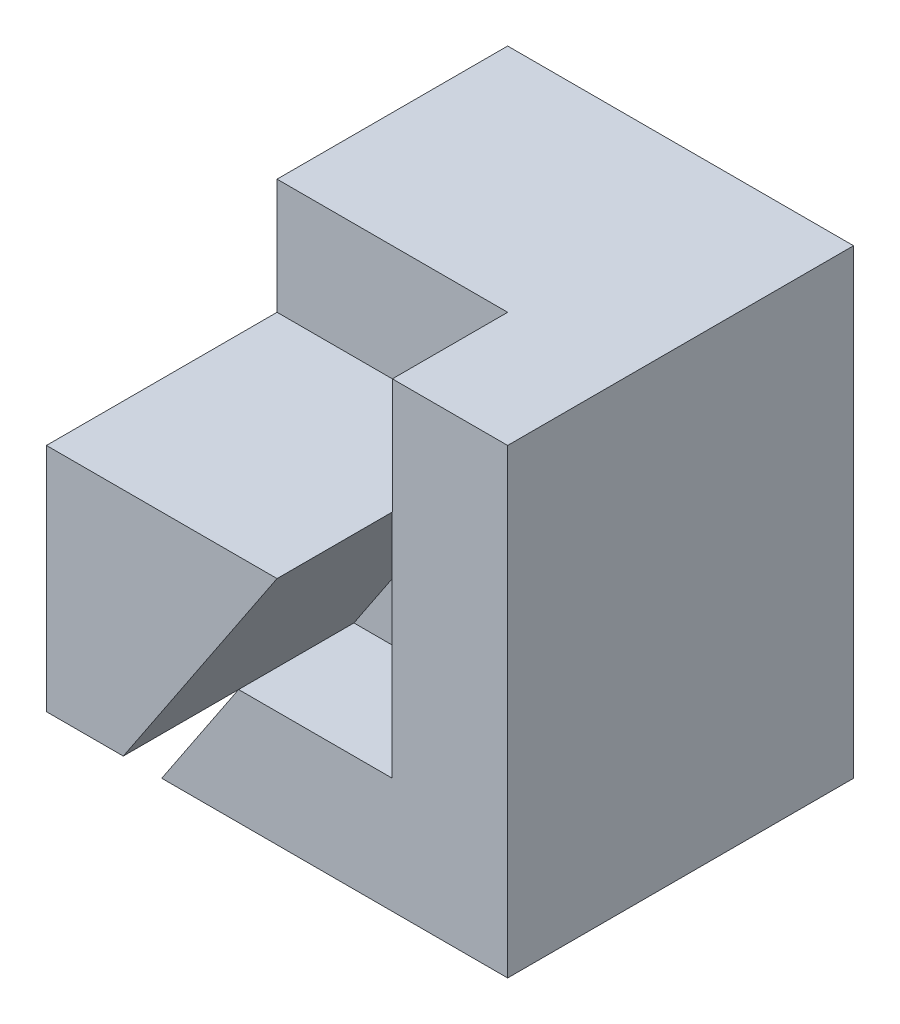
from build123d import *

# Parameters (mm, degrees)
SKETCH1_W            = 40
SKETCH1_H            = 40
BOSS_EXTRUDE1_DEPTH  = 40
SKETCH2_W            = 10
SKETCH2_H            = 10
CUT_EXTRUDE1_DEPTH   = 40
SKETCH4_W            = 10
SKETCH4_H            = 10
SKETCH4_H_2          = 30
CUT_EXTRUDE2_DEPTH   = 40
SKETCH5_W            = 20
SKETCH5_H            = 10
CUT_EXTRUDE3_DEPTH   = 10
SKETCH7_W            = 20
SKETCH7_H            = 10
CUT_EXTRUDE16_DEPTH  = 20
SKETCH11_W           = 20
SKETCH11_H           = 20
CUT_EXTRUDE19_DEPTH  = 10
CUT_EXTRUDE20_DEPTH  = 10
SKETCH13_W           = 20
SKETCH13_H           = 10
CUT_EXTRUDE21_DEPTH  = 10
BOSS_EXTRUDE2_DEPTH  = 10
SKETCH16_W           = 20
SKETCH16_H           = 20
CUT_EXTRUDE25_DEPTH  = 10
CUT_EXTRUDE26_DEPTH  = 10
SKETCH22_W           = 20
SKETCH22_H           = 10
BOSS_EXTRUDE5_DEPTH  = 10
BOSS_EXTRUDE6_DEPTH  = 10
SKETCH24_W           = 20
SKETCH24_H           = 20
BOSS_EXTRUDE7_DEPTH  = 10
BOSS_EXTRUDE8_DEPTH  = 10
BOSS_EXTRUDE9_DEPTH  = 10
CUT_EXTRUDE27_DEPTH  = 10
BOSS_EXTRUDE12_DEPTH = 10
CUT_EXTRUDE30_DEPTH  = 20
CUT_EXTRUDE31_DEPTH  = 10
SKETCH32_W           = 10
SKETCH32_H           = 19.95
CUT_EXTRUDE36_DEPTH  = 10
SKETCH33_W           = 0.033333333
SKETCH33_H           = 10
CUT_EXTRUDE37_DEPTH  = 10
BOSS_EXTRUDE13_DEPTH = 10
CUT_EXTRUDE40_DEPTH  = 20


with BuildPart() as part:
    # Sketch1 → Boss-Extrude1 (new body)
    with BuildSketch(Plane.XY):
        with Locations((20, 20)):
            Rectangle(SKETCH1_W, SKETCH1_H)
    extrude(amount=BOSS_EXTRUDE1_DEPTH)

    # Sketch2 → Cut-Extrude1 (cut)
    with BuildSketch(Plane.XY.offset(40)):
        with Locations((5, 35)):
            Rectangle(SKETCH2_W, SKETCH2_H)
    extrude(amount=-CUT_EXTRUDE1_DEPTH, mode=Mode.SUBTRACT)

    # Sketch4 → Cut-Extrude2 (cut)
    with BuildSketch(Plane(origin=(0, 40, 0), x_dir=(1, 0, 0), z_dir=(0, 1, 0))):
        with Locations((35, -35)):
            Rectangle(SKETCH4_W, SKETCH4_H)
        with Locations((5, -25)):
            Rectangle(SKETCH4_W, SKETCH4_H_2)
    extrude(amount=-CUT_EXTRUDE2_DEPTH, mode=Mode.SUBTRACT)

    # Sketch5 → Cut-Extrude3 (cut)
    with BuildSketch(Plane.XY.offset(40)):
        with Locations((20, 5)):
            Rectangle(SKETCH5_W, SKETCH5_H)
    extrude(amount=-CUT_EXTRUDE3_DEPTH, mode=Mode.SUBTRACT)

    # Sketch7 → Cut-Extrude16 (cut)
    with BuildSketch(Plane.XY.offset(40)):
        with Locations((20, 35)):
            Rectangle(SKETCH7_W, SKETCH7_H)
    extrude(amount=-CUT_EXTRUDE16_DEPTH, mode=Mode.SUBTRACT)

    # Sketch11 → Cut-Extrude19 (cut)
    with BuildSketch(Plane.XY.offset(40)):
        with Locations((20, 20)):
            Rectangle(SKETCH11_W, SKETCH11_H)
    extrude(amount=-CUT_EXTRUDE19_DEPTH, mode=Mode.SUBTRACT)

    # Sketch12 → Cut-Extrude20 (cut)
    with BuildSketch(Plane(origin=(0, 0, 0), x_dir=(-1, 0, 0), z_dir=(0, 0, -1))):
        Polygon((-10, 30), (-40, 40), (-10, 40), align=None)
    extrude(amount=-CUT_EXTRUDE20_DEPTH, mode=Mode.SUBTRACT)

    # Sketch13 → Cut-Extrude21 (cut)
    with BuildSketch(Plane.XY.offset(20)):
        with Locations((20, 35)):
            Rectangle(SKETCH13_W, SKETCH13_H)
    extrude(amount=-CUT_EXTRUDE21_DEPTH, mode=Mode.SUBTRACT)

    # Sketch15 → Boss-Extrude2 (add)
    with BuildSketch(Plane(origin=(0, 0, 0), x_dir=(-1, 0, 0), z_dir=(0, 0, -1))):
        Polygon((-40, 40), (-10, 40), (-10, 30), align=None)
    extrude(amount=-BOSS_EXTRUDE2_DEPTH)

    # Sketch16 → Cut-Extrude25 (cut)
    with BuildSketch(Plane.XY.offset(30)):
        with Locations((20, 20)):
            Rectangle(SKETCH16_W, SKETCH16_H)
    extrude(amount=-CUT_EXTRUDE25_DEPTH, mode=Mode.SUBTRACT)

    # Sketch19 → Cut-Extrude26 (cut)
    with BuildSketch(Plane.XY.offset(30)):
        Polygon((10, 0), (30, 30), (10, 30), align=None)
    extrude(amount=-CUT_EXTRUDE26_DEPTH, mode=Mode.SUBTRACT)

    # Sketch22 → Boss-Extrude5 (add)
    with BuildSketch(Plane.XY.offset(10)):
        with Locations((20, 35)):
            Rectangle(SKETCH22_W, SKETCH22_H)
    extrude(amount=BOSS_EXTRUDE5_DEPTH)

    # Sketch23 → Boss-Extrude6 (add)
    with BuildSketch(Plane.XY.offset(20)):
        Polygon((16.666666667, 10), (10, 10), (10, 0), align=None)
    extrude(amount=BOSS_EXTRUDE6_DEPTH)

    # Sketch24 → Boss-Extrude7 (add)
    with BuildSketch(Plane.XY.offset(20)):
        with Locations((20, 20)):
            Rectangle(SKETCH24_W, SKETCH24_H)
    extrude(amount=BOSS_EXTRUDE7_DEPTH)

    # Sketch25 → Boss-Extrude8 (add)
    with BuildSketch(Plane.XY.offset(30)):
        Polygon((10, 0), (30, 30), (10, 30), align=None)
    extrude(amount=BOSS_EXTRUDE8_DEPTH)

    # Sketch26 → Boss-Extrude9 (add)
    with BuildSketch(Plane.XY.offset(30)):
        Polygon((30, 30), (30, 10), (16.666666667, 10), align=None)
    extrude(amount=BOSS_EXTRUDE9_DEPTH)

    # Sketch27 → Cut-Extrude27 (cut)
    with BuildSketch(Plane.XY.offset(40)):
        Polygon((10, 0), (30, 30), (10, 30), align=None)
    extrude(amount=-CUT_EXTRUDE27_DEPTH, mode=Mode.SUBTRACT)

    # Sketch28 → Boss-Extrude12 (add)
    with BuildSketch(Plane.XY.offset(30)):
        Polygon((10, 10), (16.666666667, 10), (30, 30), (10, 30), align=None)
        Polygon((10, 0), (16.666666667, 10), (10, 10), align=None)
    extrude(amount=BOSS_EXTRUDE12_DEPTH)

    # Sketch29 → Cut-Extrude30 (cut)
    with BuildSketch(Plane.XY.offset(40)):
        Polygon((29.966666667, 29.95), (16.666666667, 10), (29.966666667, 10), align=None)
    extrude(amount=-CUT_EXTRUDE30_DEPTH, mode=Mode.SUBTRACT)

    # Sketch30 → Cut-Extrude31 (cut)
    with BuildSketch(Plane.XY.offset(40)):
        Polygon((30, 30), (10, 30), (10, 10), (16.666666667, 10), align=None)
    extrude(amount=-CUT_EXTRUDE31_DEPTH, mode=Mode.SUBTRACT)

    # Sketch32 → Cut-Extrude36 (cut)
    with BuildSketch(Plane.ZY.offset(-29.966666667)):
        with Locations((35, 19.975)):
            Rectangle(SKETCH32_W, SKETCH32_H)
    extrude(amount=-CUT_EXTRUDE36_DEPTH, mode=Mode.SUBTRACT)

    # Sketch33 → Cut-Extrude37 (cut)
    with BuildSketch(Plane.XZ.offset(-29.95)):
        with Locations((29.983333334, 35)):
            Rectangle(SKETCH33_W, SKETCH33_H)
    extrude(amount=-CUT_EXTRUDE37_DEPTH, mode=Mode.SUBTRACT)

    # Sketch34 → Boss-Extrude13 (add)
    with BuildSketch(Plane.XY.offset(30)):
        Polygon((10, 10), (16.666666667, 10), (30, 30), (10, 30), align=None)
    extrude(amount=BOSS_EXTRUDE13_DEPTH)

    # Sketch35 → Cut-Extrude40 (cut)
    with BuildSketch(Plane.XY.offset(40)):
        Polygon((10, 0), (10, 9.999), (16.666, 9.999), align=None)
    extrude(amount=-CUT_EXTRUDE40_DEPTH, mode=Mode.SUBTRACT)


solid = part.part
